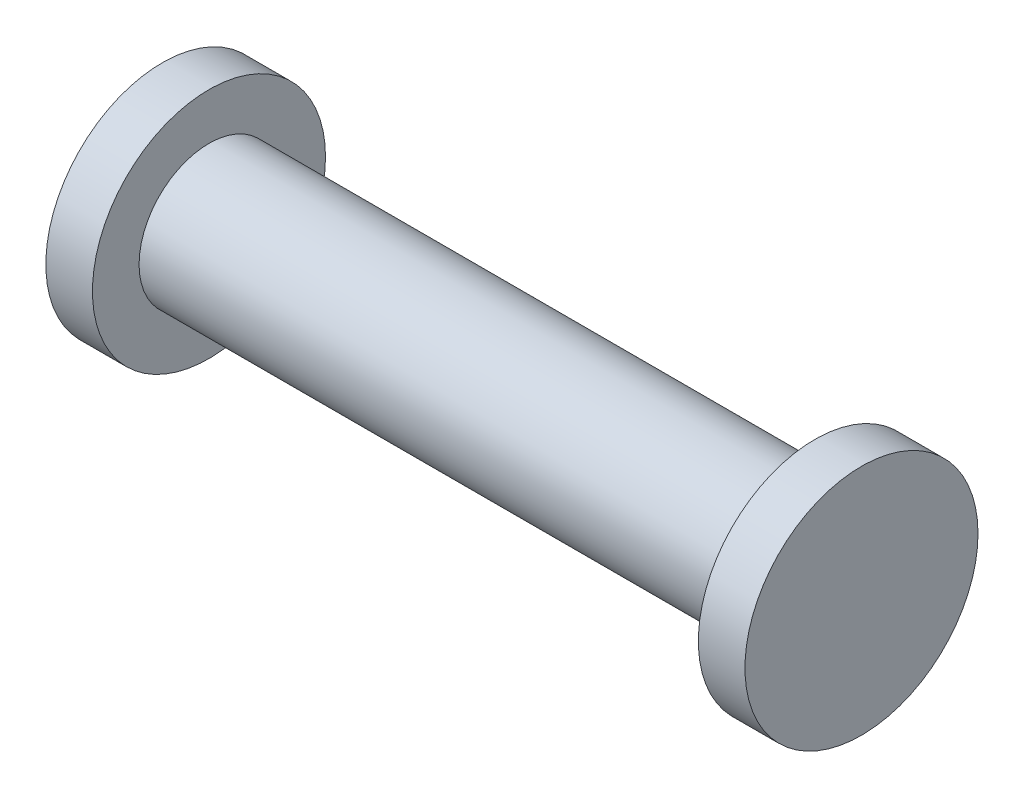
from build123d import *

# Parameters (mm, degrees)
SKETCH1_R           = 7.5
BOSS_EXTRUDE1_DEPTH = 32.5
SKETCH4_R           = 12.5
BOSS_EXTRUDE3_DEPTH = 5


with BuildPart() as part:
    # Sketch1 → Boss-Extrude1 (new, symmetric)
    with BuildSketch(Plane(origin=(0, 0, 0), x_dir=(0, 0, -1), z_dir=(1, 0, 0))):
        Circle(SKETCH1_R)
    extrude(amount=BOSS_EXTRUDE1_DEPTH, both=True)

    # Sketch4 → Boss-Extrude3 (add)
    with BuildSketch(Plane(origin=(32.5, 0, 0), x_dir=(0, 0, -1), z_dir=(1, 0, 0))):
        Circle(SKETCH4_R)
    boss_extrude3 = extrude(amount=BOSS_EXTRUDE3_DEPTH)

    # Mirror1: Boss-Extrude3 across plane
    add(boss_extrude3.mirror(Plane(origin=(0, 0, 0), x_dir=(0, 0, 1), z_dir=(1, 0, 0))))


solid = part.part
